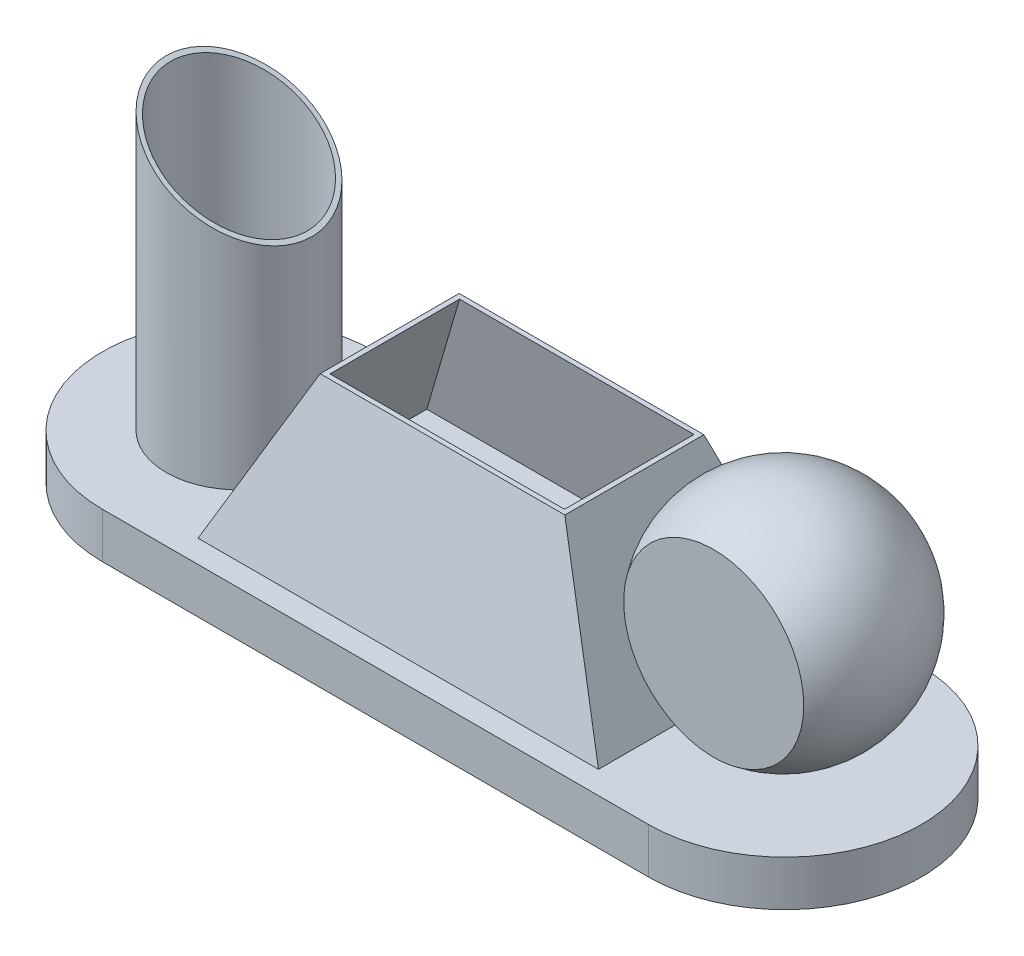
from build123d import *

# Parameters (mm, degrees)
EXTRUDE1_DEPTH = 10
SKETCH2_W      = 88
SKETCH2_H      = 50
SKETCH4_W      = 84.491556584
SKETCH4_H      = 62.317301915
EXTRUDE2_DEPTH = 25
SHELL1_T       = -1
SKETCH5_R      = 16
EXTRUDE3_DEPTH = 90
EXTRUDE4_DEPTH = 45
SHELL2_T       = -1
SKETCH10_R     = 25
EXTRUDE5_DEPTH = 90


with BuildPart() as part:
    # Sketch1 → Extrude1 (new body)
    with BuildSketch(Plane(origin=(0, 0, 0), x_dir=(1, 0, 0), z_dir=(0, 1, 0))):
        with BuildLine():
            Line((-60, 30), (60, 30))
            ThreePointArc((60, 30), (90, 0), (60, -30))
            Line((60, -30), (-60, -30))
            ThreePointArc((-60, -30), (-90, 0), (-60, 30))
        make_face()
    extrude(amount=EXTRUDE1_DEPTH)


with BuildPart() as body_2:
    # Sketch2 → Loft1 section 0
    with BuildSketch(Plane(origin=(0, 10, 0), x_dir=(1, 0, 0), z_dir=(0, 1, 0)), mode=Mode.PRIVATE) as loft1_s0:
        Rectangle(SKETCH2_W, SKETCH2_H)
    loft([loft1_s0.sketch, Vertex(0, 100, 0)])

    # Sketch4 → Extrude2 (cut, symmetric)
    with BuildSketch(Plane.XY):
        with Locations((-4.205462092, 76.158650958)):
            Rectangle(SKETCH4_W, SKETCH4_H)
    extrude(amount=EXTRUDE2_DEPTH, both=True, mode=Mode.SUBTRACT)

    # Shell1
    shell1_openings = [body_2.faces().sort_by_distance(p)[0] for p in [
        (0, 45, 0),
    ]]
    offset(amount=SHELL1_T, openings=shell1_openings, kind=Kind.INTERSECTION)


with BuildPart() as body_3:
    # Sketch5 → Extrude3 (new body)
    with BuildSketch(Plane(origin=(0, 10, 0), x_dir=(1, 0, 0), z_dir=(0, 1, 0))):
        with Locations(Location((-60, 0, 0), (0, 0, 90))):
            Circle(SKETCH5_R)
    extrude(amount=EXTRUDE3_DEPTH)

    # Sketch7 → Extrude4 (cut, symmetric)
    with BuildSketch(Plane.XY):
        Polygon((-26.888888889, 45), (-97.326267404, 85.667039446), (-97.326267404, 110.899812001), (-26.888888889, 110.899812001), align=None)
    extrude(amount=EXTRUDE4_DEPTH, both=True, mode=Mode.SUBTRACT)

    # Shell2
    shell2_openings = [body_3.faces().sort_by_distance(p)[0] for p in [
        (-60, 64.116708913, 0),
    ]]
    offset(amount=SHELL2_T, openings=shell2_openings, kind=Kind.INTERSECTION)


with BuildPart() as body_4:
    # Sketch8 → Revolve1 (revolve)
    with BuildSketch(Plane.XY):
        with BuildLine():
            Line((59.605510636, 60), (59.605510636, 10))
            ThreePointArc((59.605510636, 10), (34.605510636, 35), (59.605510636, 60))
        make_face()
    revolve(axis=Axis((59.605510636, 60, 0), (0, -1, 0)))

    # Sketch10 → Extrude5 (cut)
    with BuildSketch(Plane.XY.offset(15.277777778)):
        with Locations((59.605510636, 35)):
            Circle(SKETCH10_R)
    extrude(amount=EXTRUDE5_DEPTH, mode=Mode.SUBTRACT)


solid = Compound([part.part, body_2.part, body_3.part, body_4.part])
